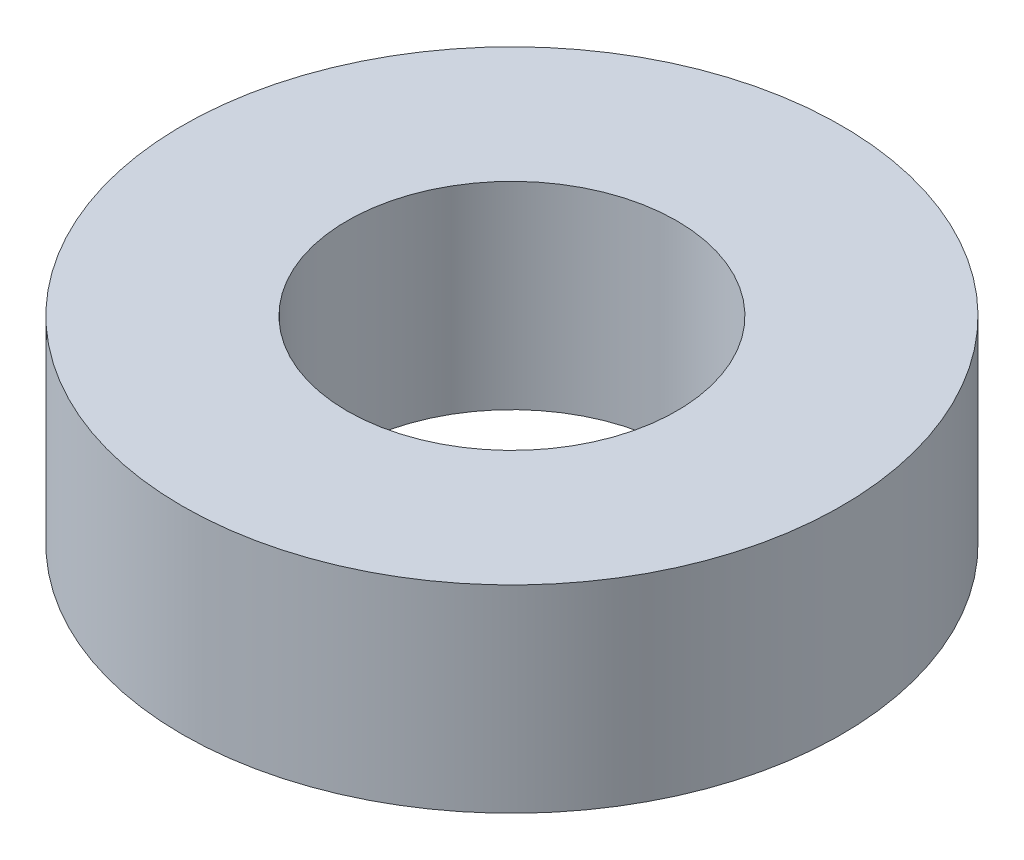
from build123d import *

# Parameters (mm, degrees)
SKETCH1_R           = 12.7
SKETCH1_R_2         = 6.35
BOSS_EXTRUDE1_DEPTH = 7.62


with BuildPart() as part:
    # Sketch1 → Boss-Extrude1 (new body)
    with BuildSketch(Plane(origin=(0, 0, 0), x_dir=(1, 0, 0), z_dir=(0, 1, 0))):
        Circle(SKETCH1_R)
        Circle(SKETCH1_R_2, mode=Mode.SUBTRACT)
    extrude(amount=BOSS_EXTRUDE1_DEPTH)


solid = part.part
